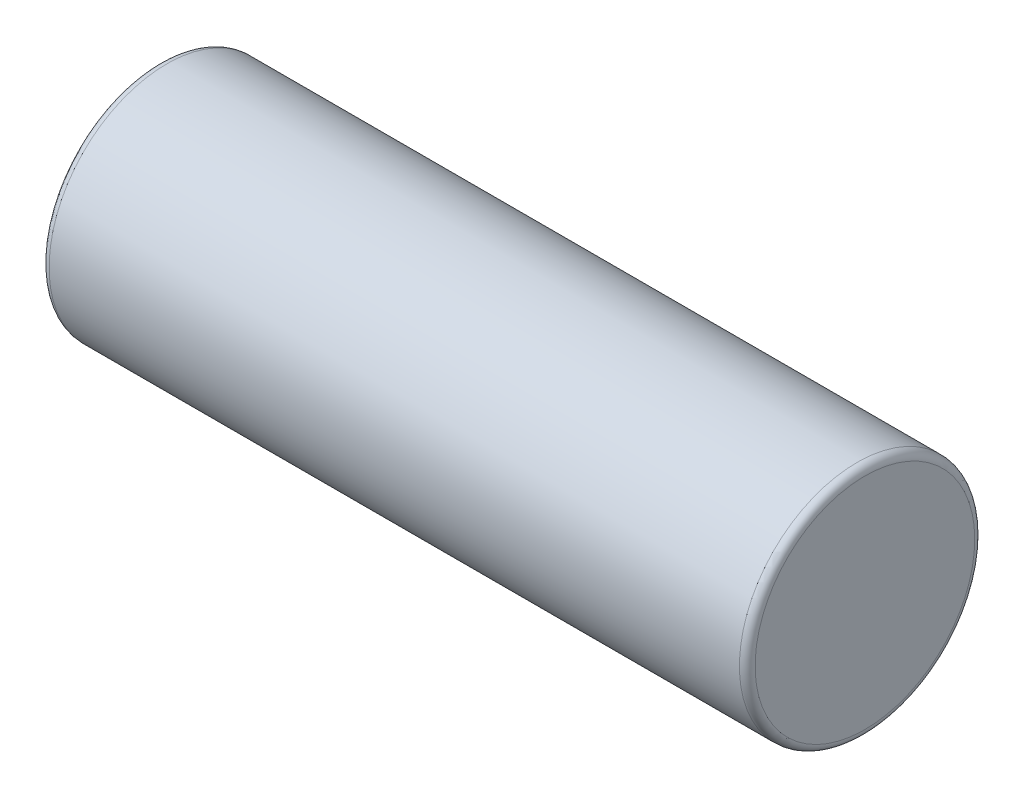
from build123d import *

# Parameters (mm, degrees)
SKETCH1_R           = 3
BOSS_EXTRUDE1_DEPTH = 9
FILLET1_R           = 0.2


with BuildPart() as part:
    # Sketch1 → Boss-Extrude1 (new body, symmetric)
    with BuildSketch(Plane(origin=(0, 0, 0), x_dir=(0, 0, -1), z_dir=(1, 0, 0))):
        Circle(SKETCH1_R)
    extrude(amount=BOSS_EXTRUDE1_DEPTH, both=True)

    # Fillet1
    fillet1_edges = [part.edges().sort_by_distance(p)[0] for p in [
        (-9, 0, 3),
        (9, 0, 3),
    ]]
    fillet(fillet1_edges, radius=FILLET1_R)


solid = part.part
